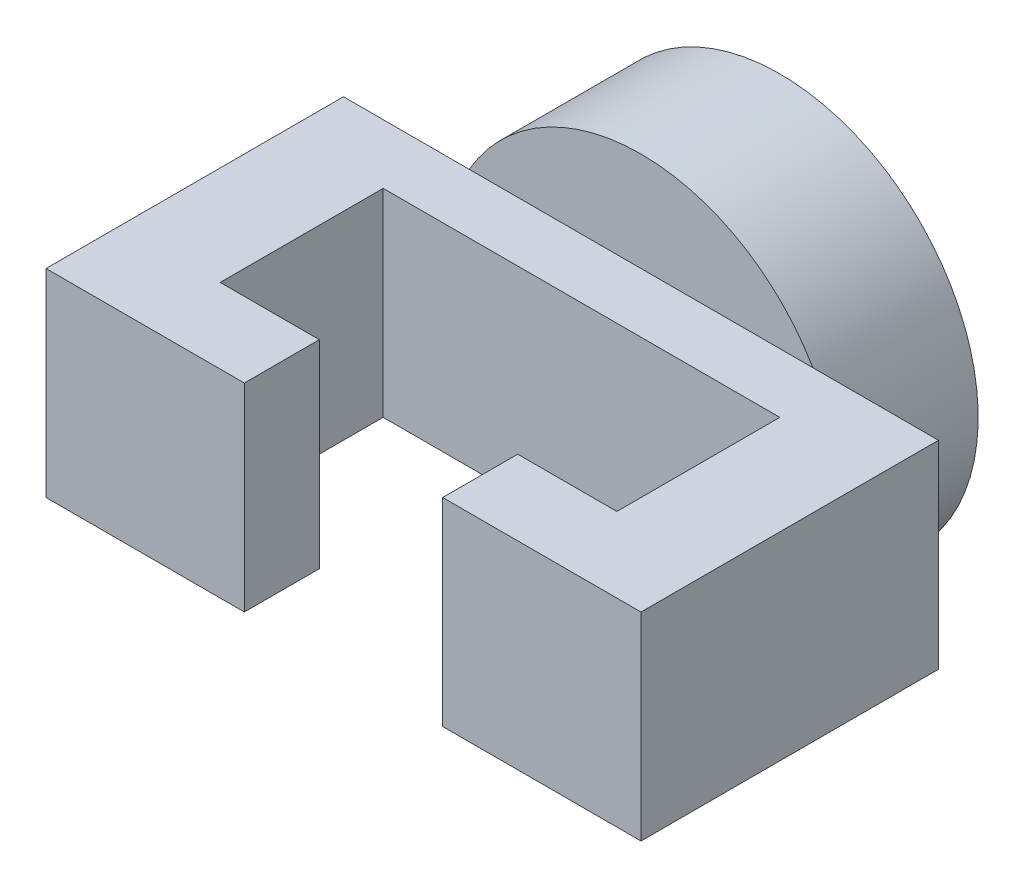
from build123d import *

# Parameters (mm, degrees)
CROQUIS1_R              = 100
SALIENTE_EXTRUIR1_DEPTH = 50
CROQUIS2_W              = 300
CROQUIS2_H              = 100
SALIENTE_EXTRUIR2_DEPTH = 150
CORTAR_EXTRUIR1_DEPTH   = 150
CROQUIS6_R              = 100
SALIENTE_EXTRUIR3_DEPTH = 20


with BuildPart() as part:
    # Croquis1 → Saliente-Extruir1 (new body)
    with BuildSketch(Plane.XY):
        Circle(CROQUIS1_R)
    extrude(amount=SALIENTE_EXTRUIR1_DEPTH)

    # Croquis2 → Saliente-Extruir2 (add)
    with BuildSketch(Plane.XY.offset(50)):
        Rectangle(CROQUIS2_W, CROQUIS2_H)
    extrude(amount=SALIENTE_EXTRUIR2_DEPTH)

    # Croquis3 → Cortar-Extruir1 (cut)
    with BuildSketch(Plane.XZ.offset(50)):
        Polygon((-100, 162.170416567), (-50, 162.170416567), (-50, 200), (50, 200), (50, 162.170416567), (100, 162.170416567), (100, 80), (-100, 80), align=None)
    extrude(amount=-CORTAR_EXTRUIR1_DEPTH, mode=Mode.SUBTRACT)

    # Croquis6 → Saliente-Extruir3 (add)
    with BuildSketch(Plane(origin=(0, 0, 0), x_dir=(-1, 0, 0), z_dir=(0, 0, -1))):
        Circle(CROQUIS6_R)
    extrude(amount=SALIENTE_EXTRUIR3_DEPTH)


solid = part.part
